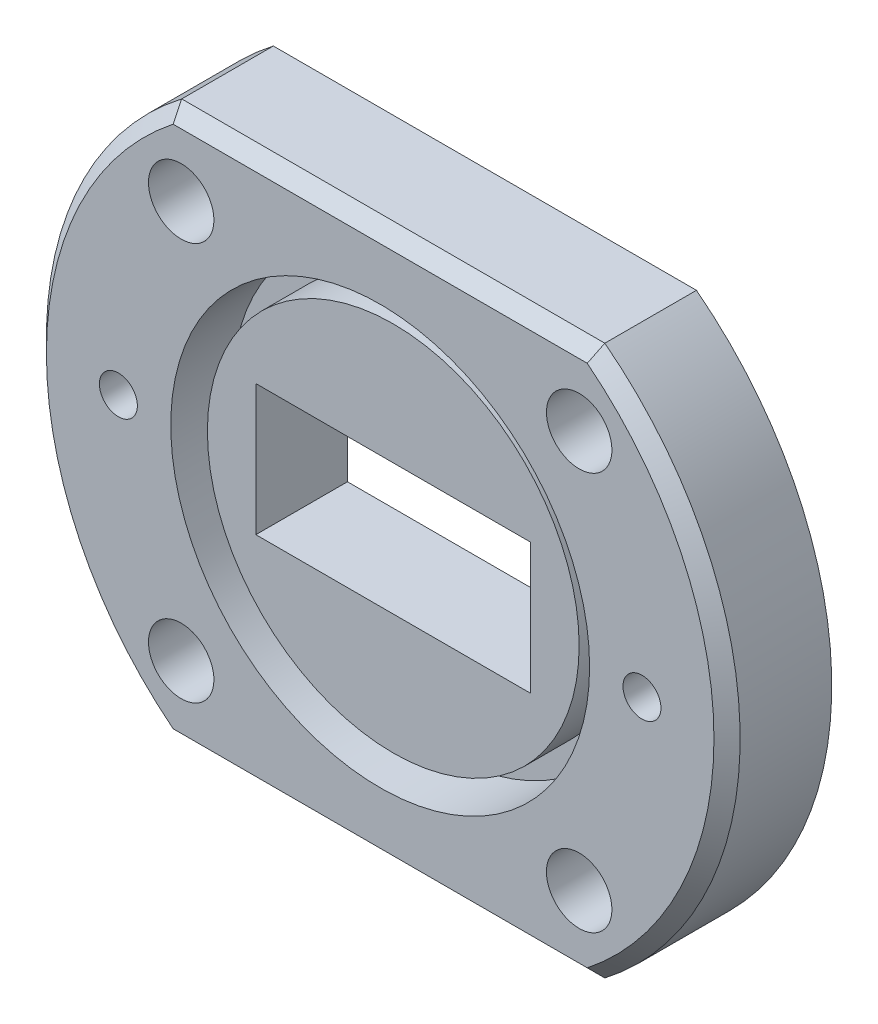
from build123d import *

# Parameters (mm, degrees)
SKETCH_1_R               = 26.5
EXTRUDE_1_DEPTH          = 8
SKETCH_2_R               = 16
CUT_EXTRUDE_1_DEPTH      = 1
SKETCH_3_R               = 16
SKETCH_3_R_2             = 14.2
CUT_EXTRUDE_2_DEPTH      = 3.7
SKETCH_4_W               = 21
SKETCH_4_H               = 10
CUT_EXTRUDE_3_DEPTH      = 8
SKETCH_5_R               = 2.5
CUT_EXTRUDE_4_DEPTH      = 9
PATTERN_CIRCULAR_1_COUNT = 4
CHAMFER_1_SIZE           = 1
SKETCH_6_W               = 30
SKETCH_6_H               = 30
M3_5X0_61_D              = 2.9
CHAMFER_2_SIZE           = 1


with BuildPart() as part:
    # Эскиз1 → Бобышка-Вытянуть1 (new body)
    with BuildSketch(Plane.XY):
        Circle(SKETCH_1_R)
    extrude(amount=EXTRUDE_1_DEPTH)

    # Эскиз2 → Вырез-Вытянуть1 (cut)
    with BuildSketch(Plane.XY.offset(8)):
        Circle(SKETCH_2_R)
    extrude(amount=-CUT_EXTRUDE_1_DEPTH, mode=Mode.SUBTRACT)

    # Эскиз3 → Вырез-Вытянуть2 (cut)
    with BuildSketch(Plane.XY.offset(7)):
        Circle(SKETCH_3_R)
        Circle(SKETCH_3_R_2, mode=Mode.SUBTRACT)
    extrude(amount=-CUT_EXTRUDE_2_DEPTH, mode=Mode.SUBTRACT)

    # Эскиз4 → Вырез-Вытянуть3 (cut, through all)
    with BuildSketch(Plane.XY.offset(7)):
        Rectangle(SKETCH_4_W, SKETCH_4_H)
    extrude(amount=-CUT_EXTRUDE_3_DEPTH, mode=Mode.SUBTRACT)

    # Эскиз5 → Вырез-Вытянуть4 (cut, through all)
    with BuildSketch(Plane.XY.offset(8)):
        with Locations((-15.202795796, 15.202795796)):
            Circle(SKETCH_5_R)
    cut_extrude_4 = extrude(amount=-CUT_EXTRUDE_4_DEPTH, mode=Mode.SUBTRACT)

    # Круговой массив1: Вырез-Вытянуть4 ×4 about axis
    pattern_circular_1_axis = Axis((0, 0, 0), (0, 0, 1))
    for i in range(1, PATTERN_CIRCULAR_1_COUNT):
        add(cut_extrude_4.rotate(pattern_circular_1_axis, i * 360 / PATTERN_CIRCULAR_1_COUNT), mode=Mode.SUBTRACT)

    # Фаска1
    chamfer_1_edges = [part.edges().sort_by_distance(p)[0] for p in [
        (-26.5, 0, 8),
    ]]
    chamfer(chamfer_1_edges, length=CHAMFER_1_SIZE)

    # Эскиз6 → Вырез-Повернуть1 (revolve, cut)
    with BuildSketch(Plane.XY):
        with Locations((15, 36)):
            Rectangle(SKETCH_6_W, SKETCH_6_H)
    cut_revolve_1 = revolve(axis=Axis((0, 0, 0), (0, 1, 0)), mode=Mode.SUBTRACT)

    # Зеркальное отражение1: Вырез-Повернуть1 across plane
    add(cut_revolve_1.mirror(Plane.ZX), mode=Mode.SUBTRACT)

    # Отверстие обработанное метчиком M3.5x0.61 (through all)
    with Locations(Plane(origin=(-20, 0, 8), x_dir=(1, 0, 0), z_dir=(0, 0, 1))):
        with Locations((0, 0)):
            m3_5x0_61 = Hole(M3_5X0_61_D / 2)

    # Зеркальное отражение2: Отверстие обработанное метчиком M3.5x0.61 across plane
    add(m3_5x0_61.mirror(Plane(origin=(0, 0, 0), x_dir=(0, 0, 1), z_dir=(1, 0, 0))), mode=Mode.SUBTRACT)

    # Фаска2
    chamfer_2_edges = [part.edges().sort_by_distance(p)[0] for p in [
        (0, -21, 8),
        (0, 21, 8),
    ]]
    chamfer(chamfer_2_edges, length=CHAMFER_2_SIZE)


solid = part.part
